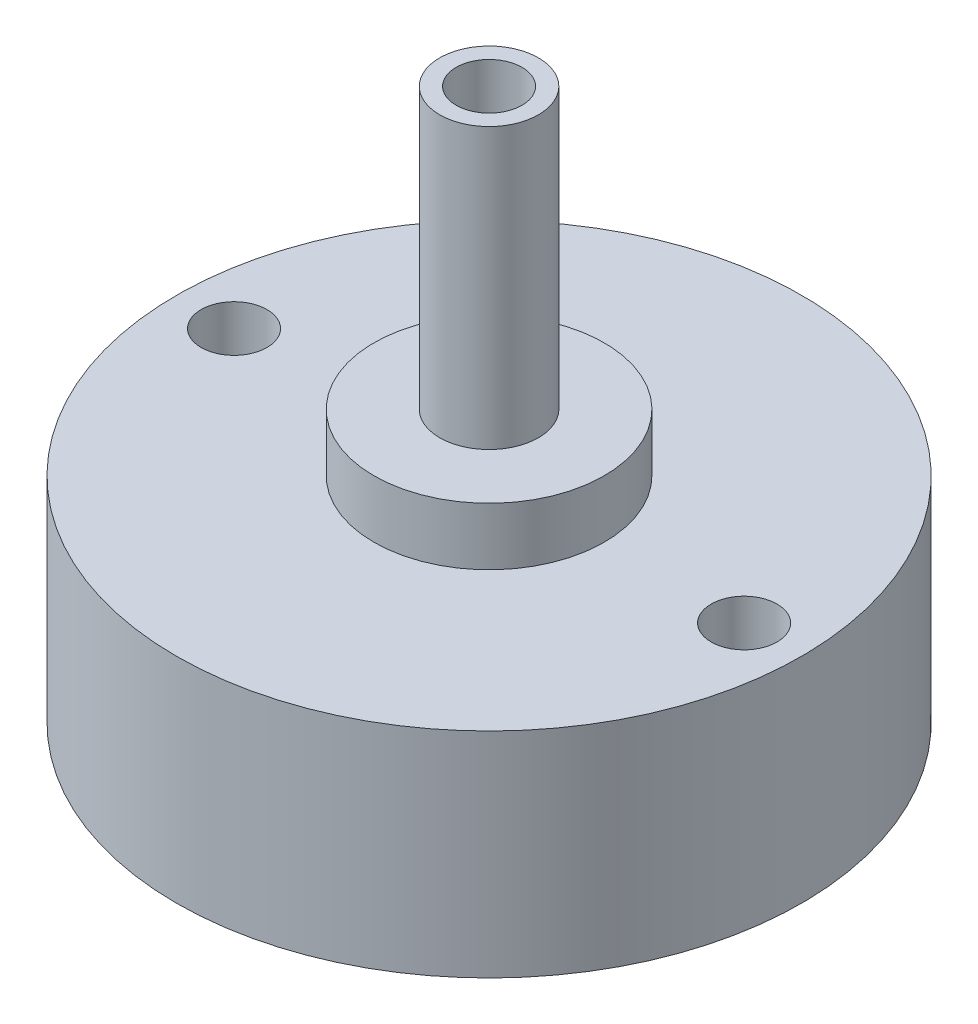
from build123d import *

# Parameters (mm, degrees)
IZIM1_R                     = 19
Y_KSEKLIK_EKSTR_ZYON1_DEPTH = 13
IZIM2_R                     = 2
KES_EKSTR_ZYON1_DEPTH       = 10
IZIM3_R                     = 7
Y_KSEKLIK_EKSTR_ZYON2_DEPTH = 3.5
IZIM4_R                     = 3
IZIM4_R_2                   = 2
Y_KSEKLIK_EKSTR_ZYON3_DEPTH = 17


with BuildPart() as part:
    # Çizim1 → Yükseklik-Ekstrüzyon1 (new body)
    with BuildSketch(Plane(origin=(0, 0, 0), x_dir=(1, 0, 0), z_dir=(0, 1, 0))):
        Circle(IZIM1_R)
    extrude(amount=-Y_KSEKLIK_EKSTR_ZYON1_DEPTH)

    # Çizim2 → Kes-Ekstrüzyon1 (cut)
    with BuildSketch(Plane(origin=(0, 0, 0), x_dir=(1, 0, 0), z_dir=(0, 1, 0))):
        with Locations((-15.5, 0)):
            Circle(IZIM2_R)
        with Locations((15.5, 0)):
            Circle(IZIM2_R)
    extrude(amount=-KES_EKSTR_ZYON1_DEPTH, mode=Mode.SUBTRACT)

    # Çizim3 → Yükseklik-Ekstrüzyon2 (add)
    with BuildSketch(Plane(origin=(0, 0, 0), x_dir=(1, 0, 0), z_dir=(0, 1, 0))):
        Circle(IZIM3_R)
    extrude(amount=Y_KSEKLIK_EKSTR_ZYON2_DEPTH)

    # Çizim4 → Yükseklik-Ekstrüzyon3 (add)
    with BuildSketch(Plane(origin=(0, 3.5, 0), x_dir=(1, 0, 0), z_dir=(0, 1, 0))):
        Circle(IZIM4_R)
        Circle(IZIM4_R_2, mode=Mode.SUBTRACT)
    extrude(amount=Y_KSEKLIK_EKSTR_ZYON3_DEPTH)


solid = part.part
